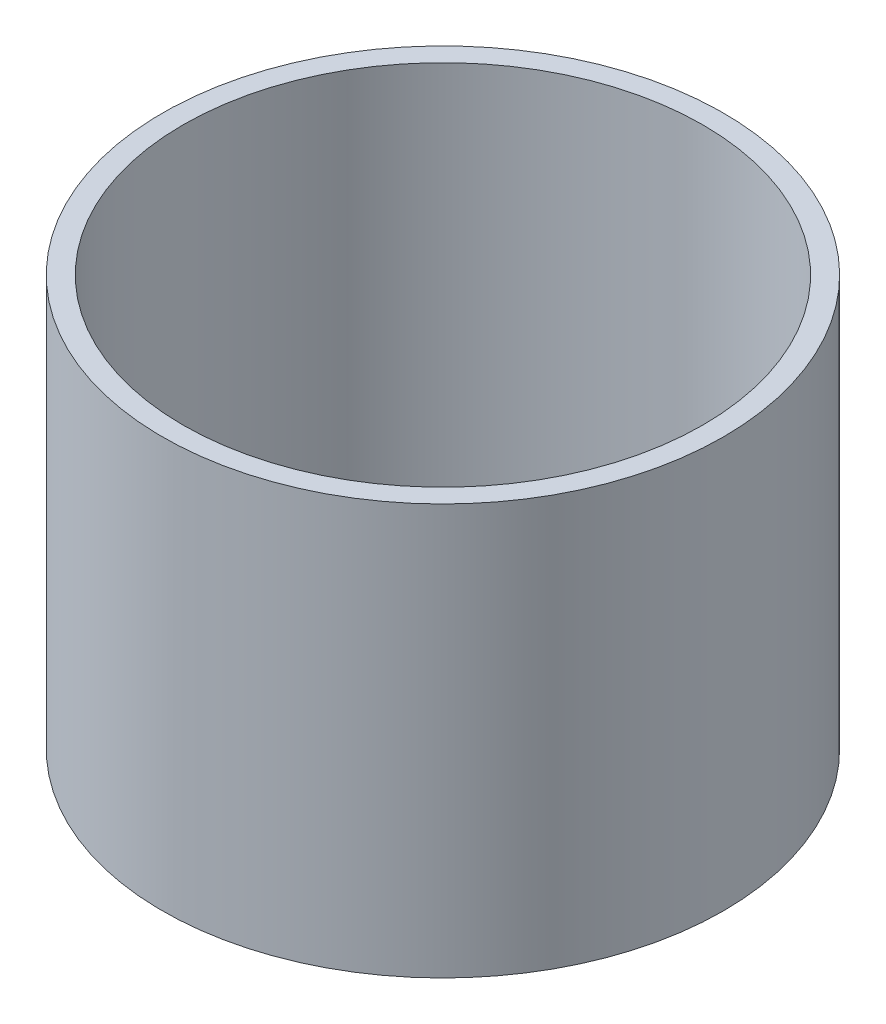
from build123d import *


with BuildPart() as part:
    # Sketch2 → Revolve2 (revolve)
    with BuildSketch(Plane.XY):
        Polygon((20.5, 30), (20.5, 0), (6, -5.277568397), (4.5, -5.277568397), (19, 0), (19, 30), align=None)
    revolve(axis=Axis((0, -1000, 0), (0, 1, 0)))


solid = part.part
